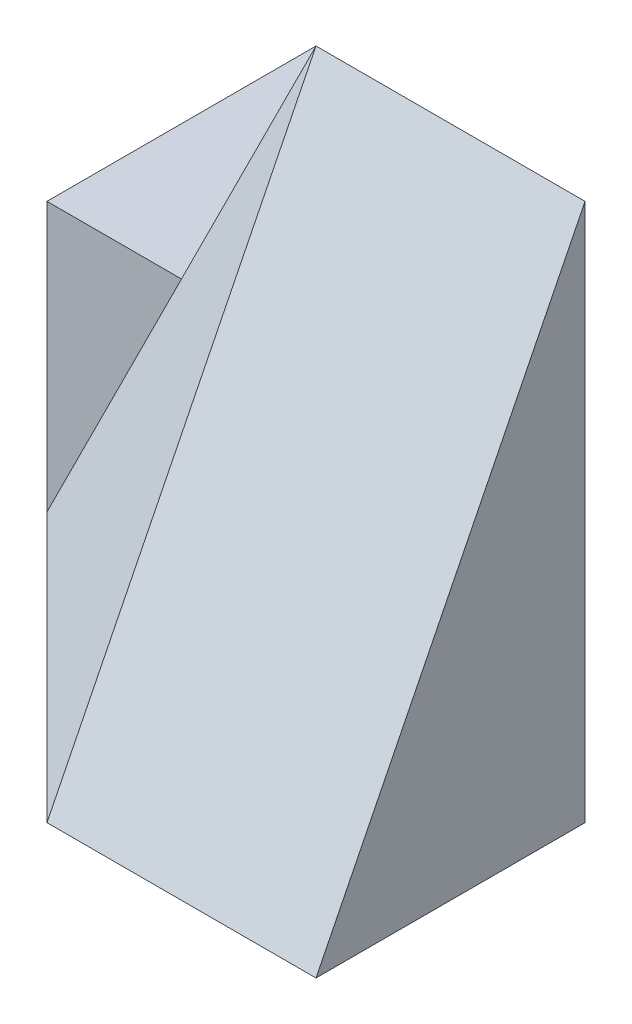
from build123d import *

# Parameters (mm, degrees)
SKETCH1_W           = 40
SKETCH1_H           = 20
BOSS_EXTRUDE1_DEPTH = 40
CUT_EXTRUDE1_DEPTH  = 40
CUT_EXTRUDE2_DEPTH  = 40
BOSS_EXTRUDE2_DEPTH = 20
BOSS_EXTRUDE3_DEPTH = 20
SKETCH6_W           = 40
SKETCH6_H           = 40
CUT_EXTRUDE3_DEPTH  = 20
SKETCH7_W           = 28.284271247
SKETCH7_H           = 20
CUT_EXTRUDE4_DEPTH  = 20
SKETCH8_W           = 20
SKETCH8_H           = 20
CUT_EXTRUDE5_DEPTH  = 20
CUT_EXTRUDE6_DEPTH  = 20
CUT_EXTRUDE7_DEPTH  = 20
SKETCH11_W          = 20
SKETCH11_H          = 20
CUT_EXTRUDE8_DEPTH  = 20
SKETCH12_W          = 20
SKETCH12_H          = 20
BOSS_EXTRUDE4_DEPTH = 20
CUT_EXTRUDE9_DEPTH  = 20
CUT_EXTRUDE10_DEPTH = 20


with BuildPart() as part:
    # Sketch1 → Boss-Extrude1 (new body)
    with BuildSketch(Plane.XY):
        with Locations((20, 10)):
            Rectangle(SKETCH1_W, SKETCH1_H)
    extrude(amount=BOSS_EXTRUDE1_DEPTH)

    # Sketch2 → Cut-Extrude1 (cut)
    with BuildSketch(Plane(origin=(0, 20, 0), x_dir=(1, 0, 0), z_dir=(0, 1, 0))):
        Polygon((0, -20), (20, -40), (0, -40), align=None)
    extrude(amount=-CUT_EXTRUDE1_DEPTH, mode=Mode.SUBTRACT)

    # Sketch3 → Cut-Extrude2 (cut)
    with BuildSketch(Plane(origin=(0, 20, 0), x_dir=(1, 0, 0), z_dir=(0, 1, 0))):
        Polygon((20, -40), (20, -20), (0, -20), align=None)
    extrude(amount=-CUT_EXTRUDE2_DEPTH, mode=Mode.SUBTRACT)

    # Sketch4 → Boss-Extrude2 (add)
    with BuildSketch(Plane(origin=(0, 20, 0), x_dir=(1, 0, 0), z_dir=(0, 1, 0))):
        Polygon((0, 0), (0, -20), (40, -20), (20, 0), align=None)
    extrude(amount=BOSS_EXTRUDE2_DEPTH)

    # Sketch5 → Boss-Extrude3 (add)
    with BuildSketch(Plane(origin=(-8.888888889, 4.444444444, 8.888888889), x_dir=(0.745355992, 0.298142397, 0.596284794), z_dir=(-0.666666667, 0.333333333, 0.666666667))):
        Polygon((11.92569588, -8.94427191), (38.75851161, -17.88854382), (38.75851161, 26.83281573), align=None)
    extrude(amount=-BOSS_EXTRUDE3_DEPTH)

    # Sketch6 → Cut-Extrude3 (cut)
    with BuildSketch(Plane.XZ):
        with Locations((20, 20)):
            Rectangle(SKETCH6_W, SKETCH6_H)
    extrude(amount=CUT_EXTRUDE3_DEPTH, mode=Mode.SUBTRACT)

    # Sketch7 → Cut-Extrude4 (cut)
    with BuildSketch(Plane(origin=(10, 0, -10), x_dir=(-0.707106781, 0, -0.707106781), z_dir=(0.707106781, 0, -0.707106781))):
        with Locations((-28.284271248, 30)):
            Rectangle(SKETCH7_W, SKETCH7_H)
    extrude(amount=CUT_EXTRUDE4_DEPTH, mode=Mode.SUBTRACT)

    # Sketch8 → Cut-Extrude5 (cut)
    with BuildSketch(Plane(origin=(20, 0, 0), x_dir=(0, 0, -1), z_dir=(1, 0, 0))):
        with Locations((-30, 30)):
            Rectangle(SKETCH8_W, SKETCH8_H)
    extrude(amount=CUT_EXTRUDE5_DEPTH, mode=Mode.SUBTRACT)

    # Sketch9 → Cut-Extrude6 (cut)
    with BuildSketch(Plane.XY.offset(20)):
        Polygon((0, 40), (0, 20), (10, 20), (20, 40), align=None)
    extrude(amount=-CUT_EXTRUDE6_DEPTH, mode=Mode.SUBTRACT)

    # Sketch10 → Cut-Extrude7 (cut)
    with BuildSketch(Plane(origin=(0, 20, 0), x_dir=(1, 0, 0), z_dir=(0, 1, 0))):
        Polygon((40, 0), (40, -20), (20, 0), align=None)
    extrude(amount=-CUT_EXTRUDE7_DEPTH, mode=Mode.SUBTRACT)

    # Sketch11 → Cut-Extrude8 (cut)
    with BuildSketch(Plane.XY.offset(20)):
        with Locations((30, 30)):
            Rectangle(SKETCH11_W, SKETCH11_H)
    extrude(amount=-CUT_EXTRUDE8_DEPTH, mode=Mode.SUBTRACT)

    # Sketch12 → Boss-Extrude4 (add)
    with BuildSketch(Plane.XY.offset(40)):
        with Locations((30, 30)):
            Rectangle(SKETCH12_W, SKETCH12_H)
    extrude(amount=-BOSS_EXTRUDE4_DEPTH)

    # Sketch14 → Cut-Extrude9 (cut)
    with BuildSketch(Plane(origin=(20, 0, 0), x_dir=(0, 0, -1), z_dir=(1, 0, 0))):
        Polygon((-20, 40), (-10, 30), (0, 40), align=None)
        Polygon((0, 40), (-10, 30), (0, 20), align=None)
    extrude(amount=-CUT_EXTRUDE9_DEPTH, mode=Mode.SUBTRACT)

    # Sketch15 → Cut-Extrude10 (cut)
    with BuildSketch(Plane.ZY.offset(-20)):
        Polygon((20, 40), (40, 0), (40, 40), align=None)
    extrude(amount=-CUT_EXTRUDE10_DEPTH, mode=Mode.SUBTRACT)


solid = part.part
